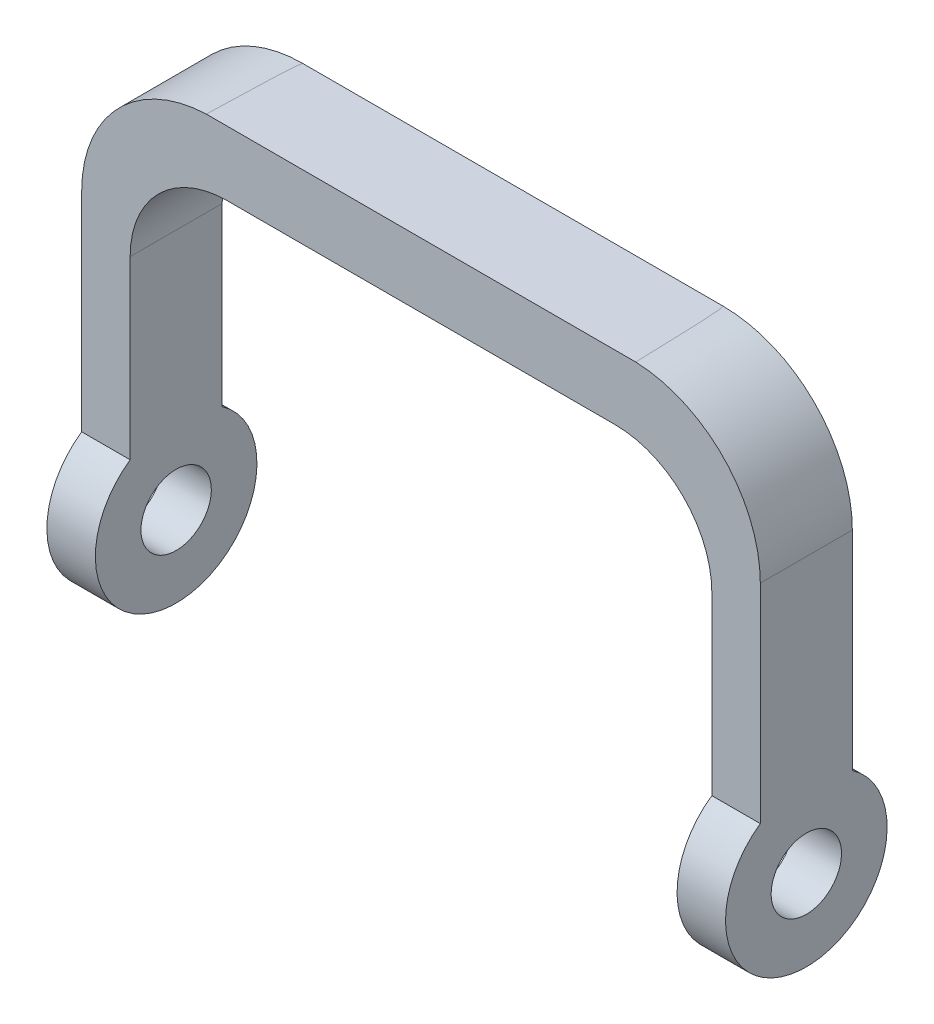
from build123d import *

# Parameters (mm, degrees)
EXTRUDE_1_DEPTH     = 100
CUT_EXTRUDE_1_DEPTH = 101
SKETCH_3_OUTSIDE_W  = 207.148
SKETCH_3_OUTSIDE_H  = 407.148
SKETCH_3_OUTSIDE_R  = 21.770153001
CUT_EXTRUDE_2_DEPTH = 421


with BuildPart() as part:
    # Эскиз1 → Бобышка-Вытянуть1 (new body)
    with BuildSketch(Plane.XY):
        with BuildLine():
            Line((-210, 0), (210, 0))
            Line((210, 0), (210, 220))
            ThreePointArc((210, 220), (186.568542495, 276.568542495), (130, 300))
            Line((130, 300), (-130, 300))
            ThreePointArc((-130, 300), (-186.568542495, 276.568542495), (-210, 220))
            Line((-210, 220), (-210, 0))
        make_face()
    extrude(amount=EXTRUDE_1_DEPTH)

    # Эскиз2 → Вырез-Вытянуть1 (cut, through all)
    with BuildSketch(Plane.XY.offset(100)):
        with BuildLine():
            Line((-180, 0), (180, 0))
            Line((180, 0), (180, 200))
            ThreePointArc((180, 200), (162.426406871, 242.426406871), (120, 260))
            Line((120, 260), (-120, 260))
            ThreePointArc((-120, 260), (-162.426406871, 242.426406871), (-180, 200))
            Line((-180, 200), (-180, 0))
        make_face()
    extrude(amount=-CUT_EXTRUDE_1_DEPTH, mode=Mode.SUBTRACT)

    # Эскиз3 outside → Вырез-Вытянуть2 (cut, through all)
    with BuildSketch(Plane(origin=(210, 0, 0), x_dir=(0, 0, -1), z_dir=(1, 0, 0))):
        with Locations((-50, 150)):
            Rectangle(SKETCH_3_OUTSIDE_W, SKETCH_3_OUTSIDE_H)
        with BuildLine():
            Line((-78.46975089, 299.947886103), (-21.53024911, 300))
            Line((-21.53024911, 300), (-21.53024911, 91.103202847))
            ThreePointArc((-21.53024911, 91.103202847), (-50, 0), (-78.46975089, 91.103202847))
            Line((-78.46975089, 91.103202847), (-78.46975089, 299.947886103))
        make_face(mode=Mode.SUBTRACT)
        with Locations((-50, 50)):
            Circle(SKETCH_3_OUTSIDE_R)
    extrude(amount=-CUT_EXTRUDE_2_DEPTH, mode=Mode.SUBTRACT)


solid = part.part
